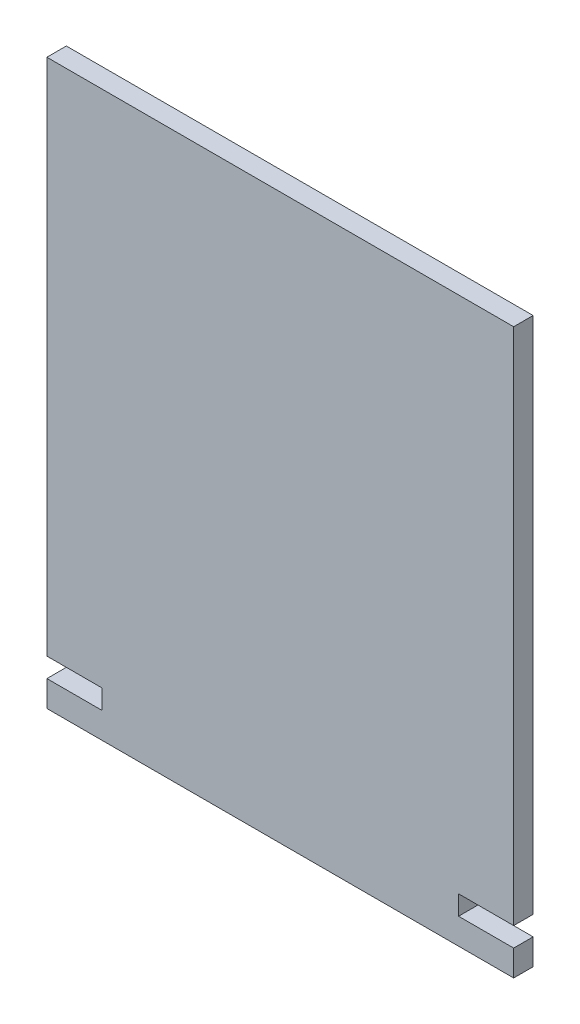
from build123d import *

# Parameters (mm, degrees)
EXTRUDE_1_DEPTH = 3


with BuildPart() as part:
    # 草图1 → 凸台-拉伸1 (new body)
    with BuildSketch(Plane.XY):
        Polygon((36, -21.528301887), (-36, -21.528301887), (-36, -17.528301887), (-27.5, -17.528301887), (-27.5, -14.528301887), (-36, -14.528301887), (-36, 65.471698113), (36, 65.471698113), (36, -14.528301887), (27.5, -14.528301887), (27.5, -17.528301887), (36, -17.528301887), align=None)
    extrude(amount=EXTRUDE_1_DEPTH)


solid = part.part
